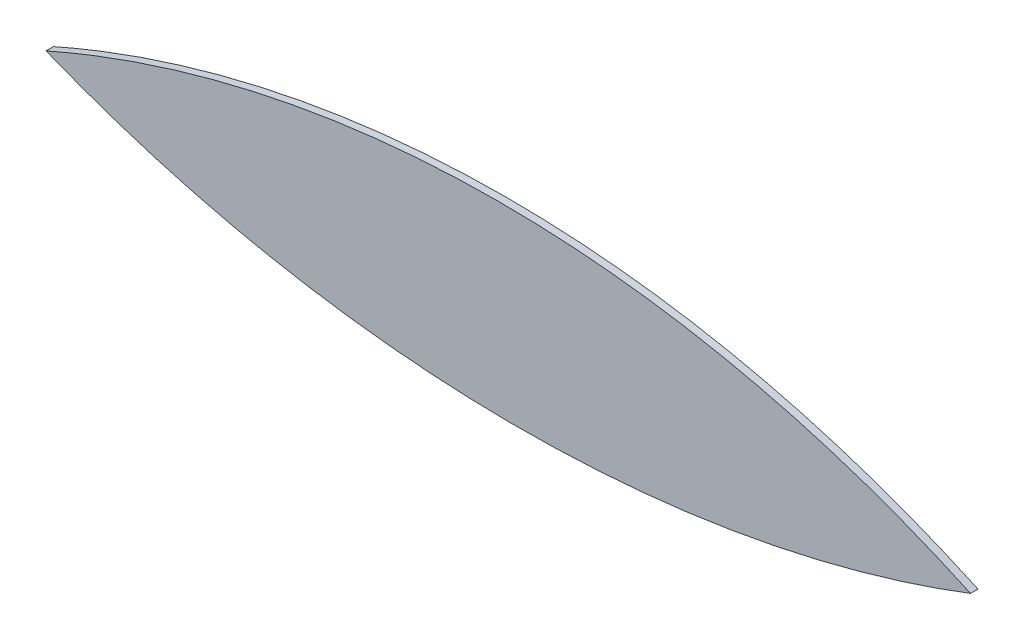
from build123d import *

# Parameters (mm, degrees)
SALIENTE_EXTRUIR1_DEPTH = 0.1


with BuildPart() as part:
    # Model → Saliente-Extruir1 (new body)
    with BuildSketch(Plane.XY):
        with BuildLine():
            add(Edge.make_bspline(
                [(59.007719811, 26.857853749), (52.845041947, 29.706883402), (46.636401811, 26.959456226)],
                knots=[0.914488287, 0.914488287, 0.914488287, 1.764140294, 1.764140294, 1.764140294], degree=2, weights=[1, 0.911110461, 1]))
            add(Edge.make_bspline(
                [(46.636401811, 26.959456226), (52.790816709, 24.473875165), (59.007719811, 26.857853749)],
                knots=[0, 0, 0, 0.914488287, 0.914488287, 0.914488287], degree=2, weights=[1, 0.897272551, 1]))
        make_face()
    extrude(amount=SALIENTE_EXTRUIR1_DEPTH)


solid = part.part
